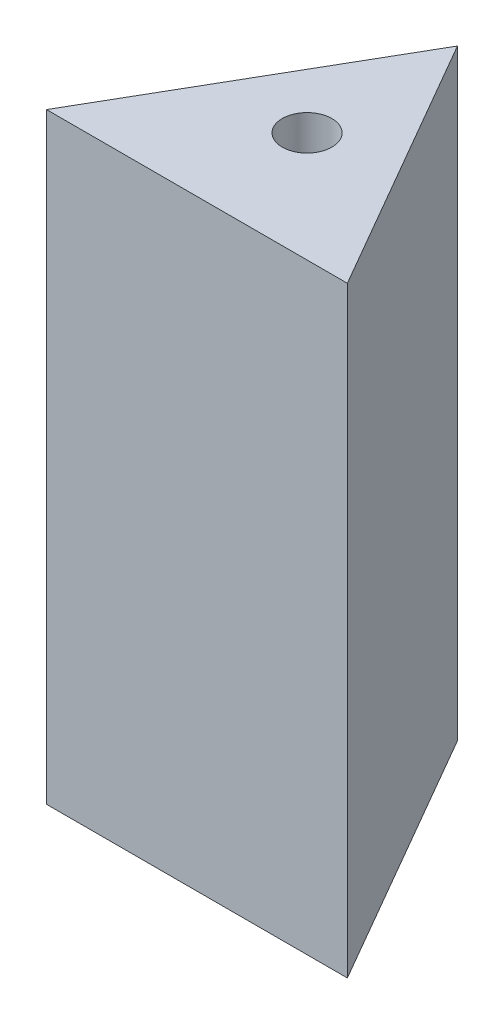
from build123d import *

# Parameters (mm, degrees)
EXTRUDE_1_DEPTH        = 40
HOLE_WIZARD_M4_1_D     = 3.3
HOLE_WIZARD_M4_1_DEPTH = 10.1
HOLE_WIZARD_M4_1_TIP   = 0.991420021
HOLE_WIZARD_M4_2_D     = 3.3
HOLE_WIZARD_M4_2_DEPTH = 10.1
HOLE_WIZARD_M4_2_TIP   = 0.991420021
HOLE_WIZARD_M4_3_D     = 3.3
HOLE_WIZARD_M4_3_DEPTH = 10.1
HOLE_WIZARD_M4_3_TIP   = 0.991420021


with BuildPart() as part:
    # 草图1 → 凸台-拉伸1 (new body)
    with BuildSketch(Plane(origin=(0, 0, 0), x_dir=(1, 0, 0), z_dir=(0, 1, 0))):
        Polygon((0, 0), (20, 0), (10, 17.320508076), align=None)
    extrude(amount=EXTRUDE_1_DEPTH)

    # M4 螺纹孔1
    with Locations(Plane(origin=(0, 0, 0), x_dir=(-1, 0, 0), z_dir=(0, -1, 0))):
        with Locations((-10, 7.320508076)):
            Hole(HOLE_WIZARD_M4_1_D / 2, depth=HOLE_WIZARD_M4_1_DEPTH)
            with Locations((0, 0, -(HOLE_WIZARD_M4_1_DEPTH + HOLE_WIZARD_M4_1_TIP / 2))):  # 118° drill point
                Cone(0, HOLE_WIZARD_M4_1_D / 2, HOLE_WIZARD_M4_1_TIP, mode=Mode.SUBTRACT)

    # M4 螺纹孔2
    with Locations(Plane(origin=(0, 40, 0), x_dir=(1, 0, 0), z_dir=(0, 1, 0))):
        with Locations((10, 7.320508076)):
            Hole(HOLE_WIZARD_M4_2_D / 2, depth=HOLE_WIZARD_M4_2_DEPTH)
            with Locations((0, 0, -(HOLE_WIZARD_M4_2_DEPTH + HOLE_WIZARD_M4_2_TIP / 2))):  # 118° drill point
                Cone(0, HOLE_WIZARD_M4_2_D / 2, HOLE_WIZARD_M4_2_TIP, mode=Mode.SUBTRACT)

    # M4 螺纹孔3
    with Locations(Plane(origin=(0, 0, 0), x_dir=(-0.5, 0, 0.866025404), z_dir=(-0.866025404, 0, -0.5))):
        with Locations((-10, 35), (-10, 5)):
            Hole(HOLE_WIZARD_M4_3_D / 2, depth=HOLE_WIZARD_M4_3_DEPTH)
            with Locations((0, 0, -(HOLE_WIZARD_M4_3_DEPTH + HOLE_WIZARD_M4_3_TIP / 2))):  # 118° drill point
                Cone(0, HOLE_WIZARD_M4_3_D / 2, HOLE_WIZARD_M4_3_TIP, mode=Mode.SUBTRACT)


solid = part.part
